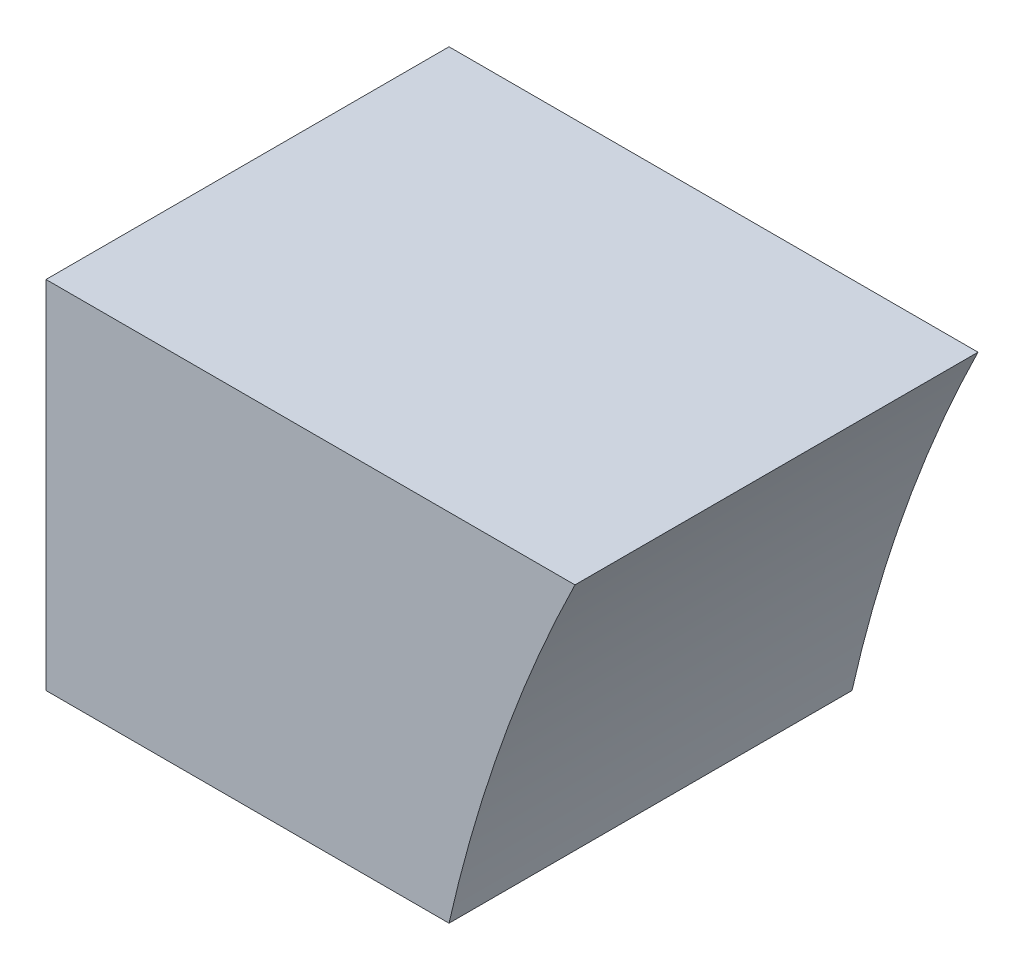
from build123d import *

# Parameters (mm, degrees)
EXTRUDE_1_DEPTH = 480
SCALE_1_SCALE   = 1.3


with BuildPart() as part:
    # 草图1 → 凸台-拉伸1 (new body)
    with BuildSketch(Plane.XY):
        with BuildLine():
            Line((-8592.598195022, 4264), (-8112.598195022, 4264))
            ThreePointArc((-8112.598195022, 4264), (-8091.25000196, 4349.188992657), (-8066.028511287, 4433.3126292))
            ThreePointArc((-8066.028511287, 4433.3126292), (-8018.870228529, 4562.510006888), (-7962.584105349, 4688))
            Line((-7962.584105349, 4688), (-8442.584105349, 4688))
            Line((-8442.584105349, 4688), (-8592.598195022, 4688))
            Line((-8592.598195022, 4688), (-8592.598195022, 4264))
        make_face()
    extrude(amount=EXTRUDE_1_DEPTH)


with BuildPart() as part_1:
    # 缩放比例1: scaled about (0, 0, 0)
    add(part.part.scale(SCALE_1_SCALE))


solid = part_1.part
